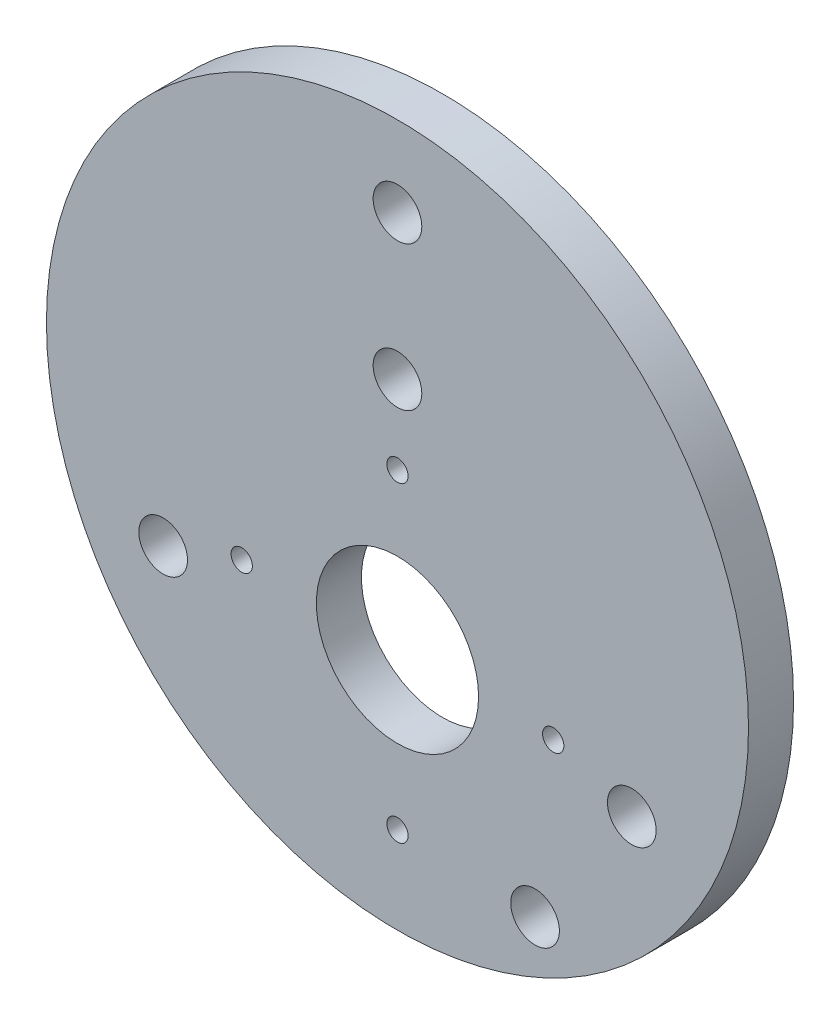
from build123d import *

# Parameters (mm, degrees)
SKETCH1_R                        = 49.4665
BOSS_EXTRUDE1_DEPTH              = 6.35
M3_SCREW_HOLE_3_0MM_DOWEL_HOLE_D = 3
SKETCH6_R                        = 3.429
CUT_EXTRUDE2_DEPTH               = 7.35
SKETCH7_R                        = 11.43
CUT_EXTRUDE3_DEPTH               = 7.35
SKETCH5_R                        = 3.429
CUT_EXTRUDE4_DEPTH               = 7.35
SKETCH11_R                       = 3.429
CUT_EXTRUDE7_DEPTH               = 7.35


with BuildPart() as part:
    # Sketch1 → Boss-Extrude1 (new body)
    with BuildSketch(Plane.XY):
        Circle(SKETCH1_R)
    extrude(amount=BOSS_EXTRUDE1_DEPTH)

    # M3 Screw Hole - Ø3.0mm Dowel Hole (through all)
    with Locations(Plane.XY.offset(6.35)):
        with Locations((0, 6.70774596), (-21.94774596, -15.24), (0, -37.18774596), (21.94774596, -15.24)):
            Hole(M3_SCREW_HOLE_3_0MM_DOWEL_HOLE_D / 2)

    # Sketch6 → Cut-Extrude2 (cut, through all)
    with BuildSketch(Plane.XY.offset(6.35)):
        with Locations((0, 38.128211777)):
            Circle(SKETCH6_R)
        with Locations((-33.02, -19.064105889)):
            Circle(SKETCH6_R)
        with Locations((33.02, -19.064105889)):
            Circle(SKETCH6_R)
    extrude(amount=-CUT_EXTRUDE2_DEPTH, mode=Mode.SUBTRACT)

    # Sketch7 → Cut-Extrude3 (cut, through all)
    with BuildSketch(Plane.XY.offset(6.35)):
        with Locations((0, -15.24)):
            Circle(SKETCH7_R)
    extrude(amount=-CUT_EXTRUDE3_DEPTH, mode=Mode.SUBTRACT)

    # Sketch5 → Cut-Extrude4 (cut, through all)
    with BuildSketch(Plane.XY.offset(6.35)):
        with Locations((0, 17.78)):
            Circle(SKETCH5_R)
    extrude(amount=-CUT_EXTRUDE4_DEPTH, mode=Mode.SUBTRACT)

    # Sketch11 → Cut-Extrude7 (cut, through all)
    with BuildSketch(Plane.XY.offset(6.35)):
        with Locations((19.38971276, -38.135544915)):
            Circle(SKETCH11_R)
    extrude(amount=-CUT_EXTRUDE7_DEPTH, mode=Mode.SUBTRACT)


solid = part.part
